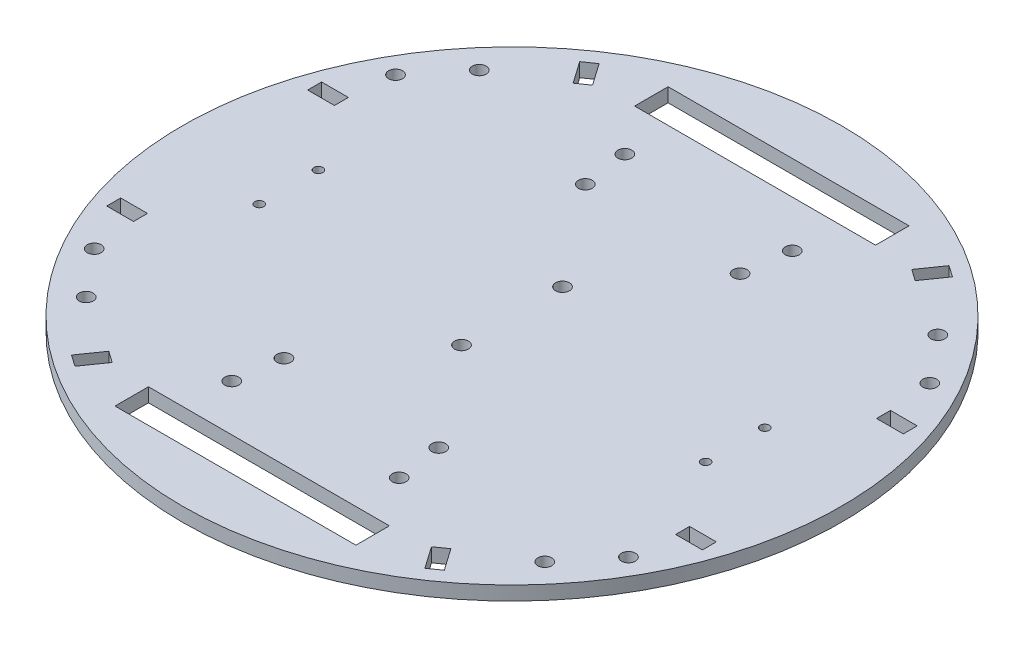
from build123d import *

# Parameters (mm, degrees)
SKETCH1_R           = 75
BOSS_EXTRUDE1_DEPTH = 3.175
SKETCH2_W           = 54.82616321
SKETCH2_H           = 7.62
CUT_EXTRUDE1_DEPTH  = 3.175
SKETCH4_R           = 1.5875
CUT_EXTRUDE2_DEPTH  = 3.175
SKETCH5_W           = 6.096
SKETCH5_H           = 3.175
CUT_EXTRUDE3_DEPTH  = 3.175
SKETCH6_R           = 1.016
CUT_EXTRUDE4_DEPTH  = 3.175


with BuildPart() as part:
    # Sketch1 → Boss-Extrude1 (new body)
    with BuildSketch(Plane(origin=(0, 0, 0), x_dir=(1, 0, 0), z_dir=(0, 1, 0))):
        Circle(SKETCH1_R)
    extrude(amount=BOSS_EXTRUDE1_DEPTH)

    # Sketch2 → Cut-Extrude1 (cut)
    with BuildSketch(Plane(origin=(0, 3.175, 0), x_dir=(1, 0, 0), z_dir=(0, 1, 0))):
        with Locations((0, 59.129220339)):
            Rectangle(SKETCH2_W, SKETCH2_H)
        with Locations((0, -59.129220339)):
            Rectangle(SKETCH2_W, SKETCH2_H)
    extrude(amount=-CUT_EXTRUDE1_DEPTH, mode=Mode.SUBTRACT)

    # Sketch4 → Cut-Extrude2 (cut)
    with BuildSketch(Plane(origin=(0, 3.175, 0), x_dir=(1, 0, 0), z_dir=(0, 1, 0))):
        with Locations((-52.180304588, 44.729838125)):
            Circle(SKETCH4_R)
        with Locations((-19.05, 44.729838125)):
            Circle(SKETCH4_R)
        with Locations((-60.791780161, 34.29)):
            Circle(SKETCH4_R)
        with Locations((-17.611780161, 34.29)):
            Circle(SKETCH4_R)
        with Locations((-60.791780161, -34.29)):
            Circle(SKETCH4_R)
        with Locations((-52.180304588, -44.729838125)):
            Circle(SKETCH4_R)
        with Locations((-17.611780161, -34.29)):
            Circle(SKETCH4_R)
        with Locations((-19.05, -44.729838125)):
            Circle(SKETCH4_R)
        with Locations((17.611780161, -34.29)):
            Circle(SKETCH4_R)
        with Locations((19.05, -44.729838125)):
            Circle(SKETCH4_R)
        with Locations((52.180304588, -44.729838125)):
            Circle(SKETCH4_R)
        with Locations((60.791780161, -34.29)):
            Circle(SKETCH4_R)
        with Locations((60.791780161, 34.29)):
            Circle(SKETCH4_R)
        with Locations((52.180304588, 44.729838125)):
            Circle(SKETCH4_R)
        with Locations((19.05, 44.729838125)):
            Circle(SKETCH4_R)
        with Locations((17.611780161, 34.29)):
            Circle(SKETCH4_R)
        with Locations((0, 11.494220339)):
            Circle(SKETCH4_R)
        with Locations((0, -11.494220339)):
            Circle(SKETCH4_R)
    extrude(amount=-CUT_EXTRUDE2_DEPTH, mode=Mode.SUBTRACT)

    # Sketch5 → Cut-Extrude3 (cut)
    with BuildSketch(Plane(origin=(0, 3.175, 0), x_dir=(1, 0, 0), z_dir=(0, 1, 0))):
        with Locations((64.732085553, 22.86)):
            Rectangle(SKETCH5_W, SKETCH5_H)
        with Locations((64.732085553, -22.86)):
            Rectangle(SKETCH5_W, SKETCH5_H)
        with Locations((-64.732085553, -22.86)):
            Rectangle(SKETCH5_W, SKETCH5_H)
        with Locations((-64.732085553, 22.86)):
            Rectangle(SKETCH5_W, SKETCH5_H)
        Polygon((39.817492218, 59.646380223), (42.418494964, 57.825553566), (38.922507782, 52.831628294), (36.321505036, 54.652454951), align=None)
        Polygon((38.922507782, -52.831628294), (42.418494964, -57.825553566), (39.817492218, -59.646380223), (36.321505036, -54.652454951), align=None)
        Polygon((-38.922507782, -52.831628294), (-36.321505036, -54.652454951), (-39.817492218, -59.646380223), (-42.418494964, -57.825553566), align=None)
        Polygon((-39.817492218, 59.646380223), (-36.321505036, 54.652454951), (-38.922507782, 52.831628294), (-42.418494964, 57.825553566), align=None)
    extrude(amount=-CUT_EXTRUDE3_DEPTH, mode=Mode.SUBTRACT)

    # Sketch6 → Cut-Extrude4 (cut)
    with BuildSketch(Plane(origin=(0, 3.175, 0), x_dir=(1, 0, 0), z_dir=(0, 1, 0))):
        with Locations((50.8, 6.731)):
            Circle(SKETCH6_R)
        with Locations((50.8, -6.731)):
            Circle(SKETCH6_R)
    cut_extrude4 = extrude(amount=-CUT_EXTRUDE4_DEPTH, mode=Mode.SUBTRACT)

    # Mirror1: Cut-Extrude4 across plane
    add(cut_extrude4.mirror(Plane(origin=(0, 0, 0), x_dir=(0, 0, 1), z_dir=(1, 0, 0))), mode=Mode.SUBTRACT)


solid = part.part
